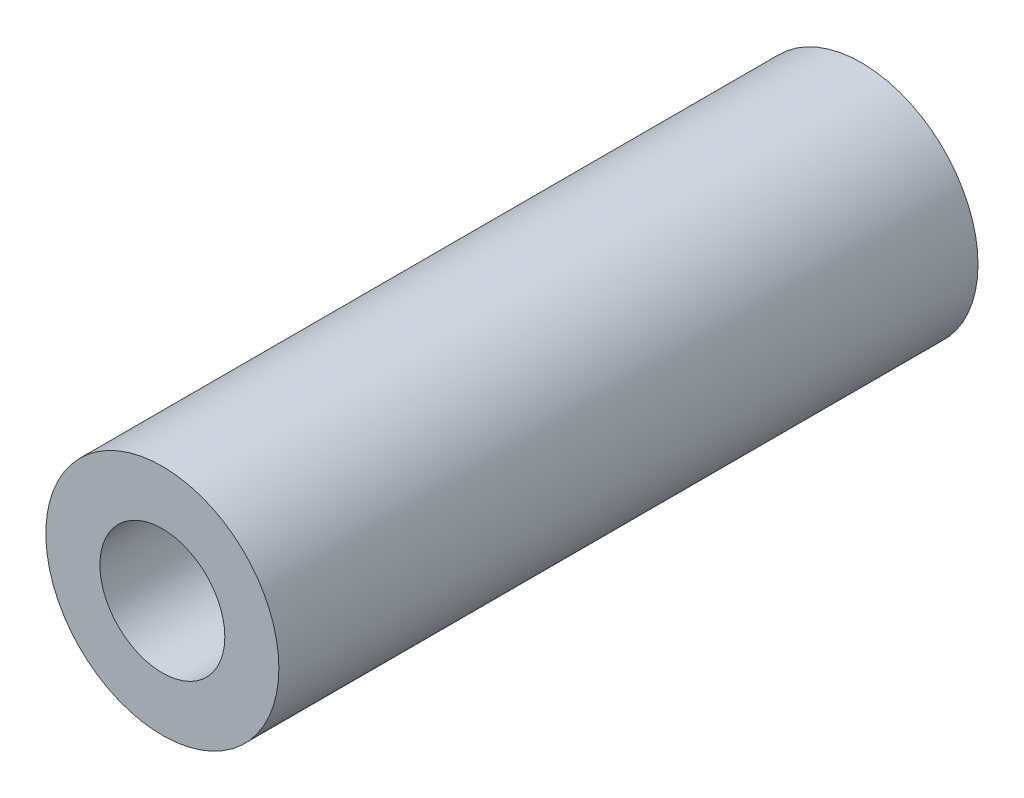
from build123d import *

# Parameters (mm, degrees)
SKETCH1_R           = 4.7625
SKETCH1_R_2         = 2.5527
BOSS_EXTRUDE1_DEPTH = 28.575


with BuildPart() as part:
    # Sketch1 → Boss-Extrude1 (new body)
    with BuildSketch(Plane.XY):
        Circle(SKETCH1_R)
        Circle(SKETCH1_R_2, mode=Mode.SUBTRACT)
    extrude(amount=BOSS_EXTRUDE1_DEPTH)


solid = part.part
